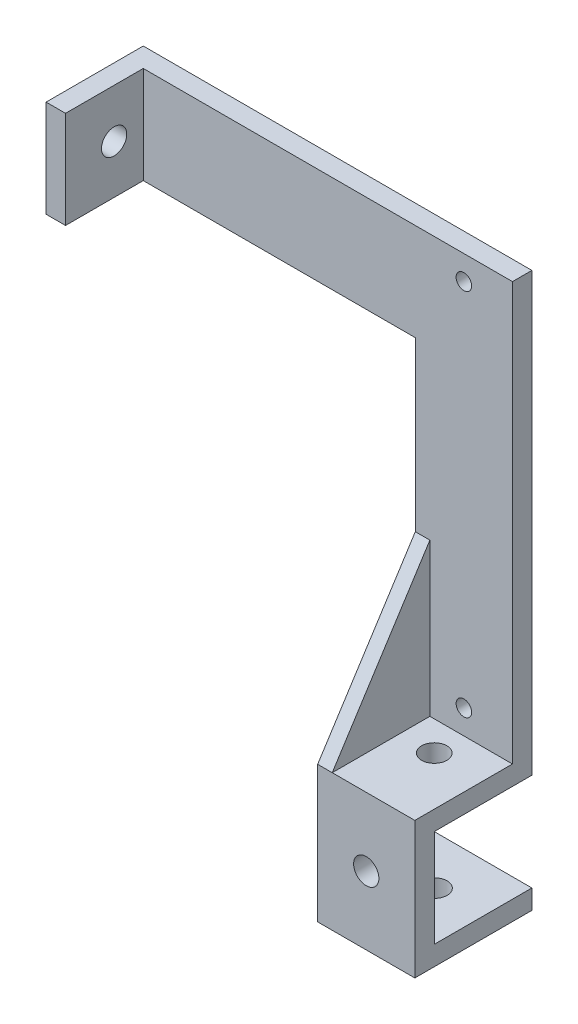
from build123d import *

# Parameters (mm, degrees)
SKETCH_1_W          = 20
SKETCH_1_H          = 90
EXTRUDE_1_DEPTH     = 4
SKETCH_2_W          = 20
SKETCH_2_H          = 4
EXTRUDE_2_DEPTH     = 20.1
SKETCH_3_W          = 20
SKETCH_3_H          = 4
EXTRUDE_3_DEPTH     = 24.1
SKETCH_4_W          = 20
SKETCH_4_H          = 4
EXTRUDE_4_DEPTH     = 20.1
SKETCH_5_R          = 2.6
CUT_EXTRUDE_1_DEPTH = 20
SKETCH_6_R          = 2.6
CUT_EXTRUDE_2_DEPTH = 20
SKETCH_7_R          = 2.6
CUT_EXTRUDE_3_DEPTH = 20
SKETCH_9_R          = 1.6
CUT_EXTRUDE_4_DEPTH = 20
EXTRUDE_6_DEPTH     = 3
SKETCH_14_W         = 4
SKETCH_14_H         = 20
EXTRUDE_7_DEPTH     = 60
SKETCH_15_W         = 4
SKETCH_15_H         = 20
EXTRUDE_8_DEPTH     = 16
SKETCH_17_R         = 2.6
CUT_EXTRUDE_6_DEPTH = 20


with BuildPart() as part:
    # 草图1 → 凸台-拉伸1 (new body)
    with BuildSketch(Plane.XY):
        with Locations((-19.209677061, -2.260885663)):
            Rectangle(SKETCH_1_W, SKETCH_1_H)
    extrude(amount=EXTRUDE_1_DEPTH)

    # 草图2 → 凸台-拉伸2 (add)
    with BuildSketch(Plane.XY.offset(4)):
        with Locations((-19.209677061, -45.260885663)):
            Rectangle(SKETCH_2_W, SKETCH_2_H)
    extrude(amount=EXTRUDE_2_DEPTH)

    # 草图3 → 凸台-拉伸3 (add)
    with BuildSketch(Plane(origin=(0, -47.260885663, 0), x_dir=(-1, 0, 0), z_dir=(0, -1, 0))):
        with Locations((19.209677061, -22.1)):
            Rectangle(SKETCH_3_W, SKETCH_3_H)
    extrude(amount=EXTRUDE_3_DEPTH)

    # 草图4 → 凸台-拉伸4 (add)
    with BuildSketch(Plane(origin=(0, 0, 20.1), x_dir=(-1, 0, 0), z_dir=(0, 0, -1))):
        with Locations((19.209677061, -69.360885663)):
            Rectangle(SKETCH_4_W, SKETCH_4_H)
    extrude(amount=EXTRUDE_4_DEPTH)

    # 草图5 → 切除-拉伸1 (cut)
    with BuildSketch(Plane(origin=(0, -47.260885663, 0), x_dir=(-1, 0, 0), z_dir=(0, -1, 0))):
        with Locations((19.209677061, -10.094759339)):
            Circle(SKETCH_5_R)
    extrude(amount=-CUT_EXTRUDE_1_DEPTH, mode=Mode.SUBTRACT)

    # 草图6 → 切除-拉伸2 (cut)
    with BuildSketch(Plane(origin=(0, 0, 20.1), x_dir=(-1, 0, 0), z_dir=(0, 0, -1))):
        with Locations((19.209677061, -57.310885663)):
            Circle(SKETCH_6_R)
    extrude(amount=-CUT_EXTRUDE_2_DEPTH, mode=Mode.SUBTRACT)

    # 草图7 → 切除-拉伸3 (cut)
    with BuildSketch(Plane(origin=(0, -67.360885663, 0), x_dir=(1, 0, 0), z_dir=(0, 1, 0))):
        with Locations((-19.209677061, -10.05)):
            Circle(SKETCH_7_R)
    extrude(amount=-CUT_EXTRUDE_3_DEPTH, mode=Mode.SUBTRACT)

    # 草图9 → 切除-拉伸4 (cut)
    with BuildSketch(Plane(origin=(0, 0, 0), x_dir=(-1, 0, 0), z_dir=(0, 0, -1))):
        with Locations((19.209677061, 37.739114337)):
            Circle(SKETCH_9_R)
        with Locations((19.209677061, -38.260885663)):
            Circle(SKETCH_9_R)
    extrude(amount=-CUT_EXTRUDE_4_DEPTH, mode=Mode.SUBTRACT)

    # 草图13 → 凸台-拉伸6 (add)
    with BuildSketch(Plane.ZY.offset(29.209677061)):
        Polygon((4, -11.848280973), (24.1, -43.260885663), (4, -43.260885663), align=None)
    extrude(amount=-EXTRUDE_6_DEPTH)

    # 草图14 → 凸台-拉伸7 (add)
    with BuildSketch(Plane.ZY.offset(29.209677061)):
        with Locations((2, 32.739114337)):
            Rectangle(SKETCH_14_W, SKETCH_14_H)
    extrude(amount=EXTRUDE_7_DEPTH)

    # 草图15 → 凸台-拉伸8 (add)
    with BuildSketch(Plane.XY.offset(4)):
        with Locations((-87.209677061, 32.739114337)):
            Rectangle(SKETCH_15_W, SKETCH_15_H)
    extrude(amount=EXTRUDE_8_DEPTH)

    # 草图17 → 切除-拉伸6 (cut)
    with BuildSketch(Plane.ZY.offset(89.209677061)):
        with Locations((10, 32.739114337)):
            Circle(SKETCH_17_R)
    extrude(amount=-CUT_EXTRUDE_6_DEPTH, mode=Mode.SUBTRACT)


solid = part.part
